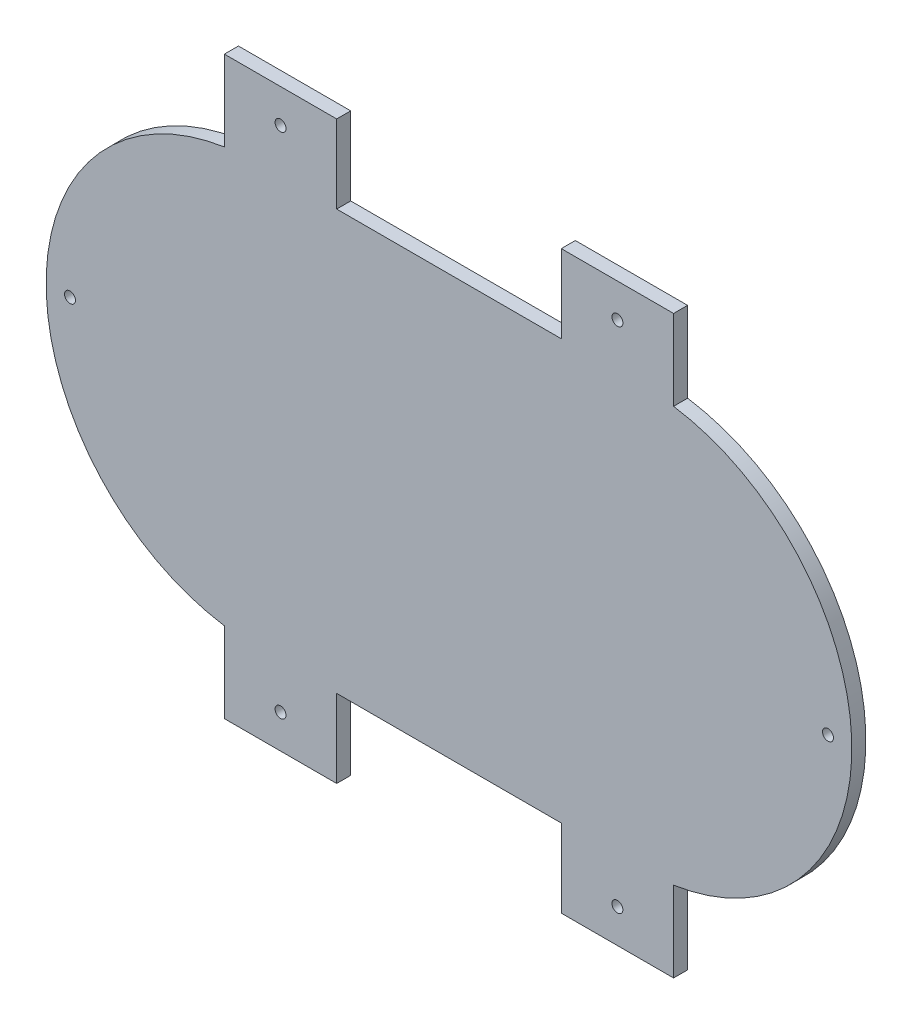
from build123d import *

# Parameters (mm, degrees)
SKETCH1_R           = 1.95
BOSS_EXTRUDE1_DEPTH = 2.5


with BuildPart() as part:
    # Sketch1 → Boss-Extrude1 (new body, symmetric)
    with BuildSketch(Plane.XY):
        with BuildLine():
            Line((133.501154847, 56.612183332), (53.501154847, 56.612183332))
            Line((53.501154847, 56.612183332), (53.501154847, 84.412183332))
            Line((53.501154847, 84.412183332), (13.501154847, 84.412183332))
            Line((13.501154847, 84.412183332), (13.501154847, 55.767785692))
            ThreePointArc((13.501154847, 55.767785692), (-49.998845153, -18.087816668), (13.501154847, -91.943419028))
            Line((13.501154847, -91.943419028), (13.501154847, -120.587816668))
            Line((13.501154847, -120.587816668), (53.501154847, -120.587816668))
            Line((53.501154847, -120.587816668), (53.501154847, -92.787816668))
            Line((53.501154847, -92.787816668), (133.501154847, -92.787816668))
            Line((133.501154847, -92.787816668), (133.501154847, -120.587816668))
            Line((133.501154847, -120.587816668), (173.501154847, -120.587816668))
            Line((173.501154847, -120.587816668), (173.501154847, -91.943419028))
            ThreePointArc((173.501154847, -91.943419028), (237.001154847, -18.087816668), (173.501154847, 55.767785692))
            Line((173.501154847, 55.767785692), (173.501154847, 84.412183332))
            Line((173.501154847, 84.412183332), (133.501154847, 84.412183332))
            Line((133.501154847, 84.412183332), (133.501154847, 56.612183332))
        make_face()
        with Locations((-41.498845153, -18.087816668)):
            Circle(SKETCH1_R, mode=Mode.SUBTRACT)
        with Locations((228.501154847, -18.087816668)):
            Circle(SKETCH1_R, mode=Mode.SUBTRACT)
        with Locations((33.501154847, 72.412183332)):
            Circle(SKETCH1_R, mode=Mode.SUBTRACT)
        with Locations((153.501154847, 72.412183332)):
            Circle(SKETCH1_R, mode=Mode.SUBTRACT)
        with Locations((33.501154847, -108.587816668)):
            Circle(SKETCH1_R, mode=Mode.SUBTRACT)
        with Locations((153.501154847, -108.587816668)):
            Circle(SKETCH1_R, mode=Mode.SUBTRACT)
    extrude(amount=BOSS_EXTRUDE1_DEPTH, both=True)


solid = part.part
